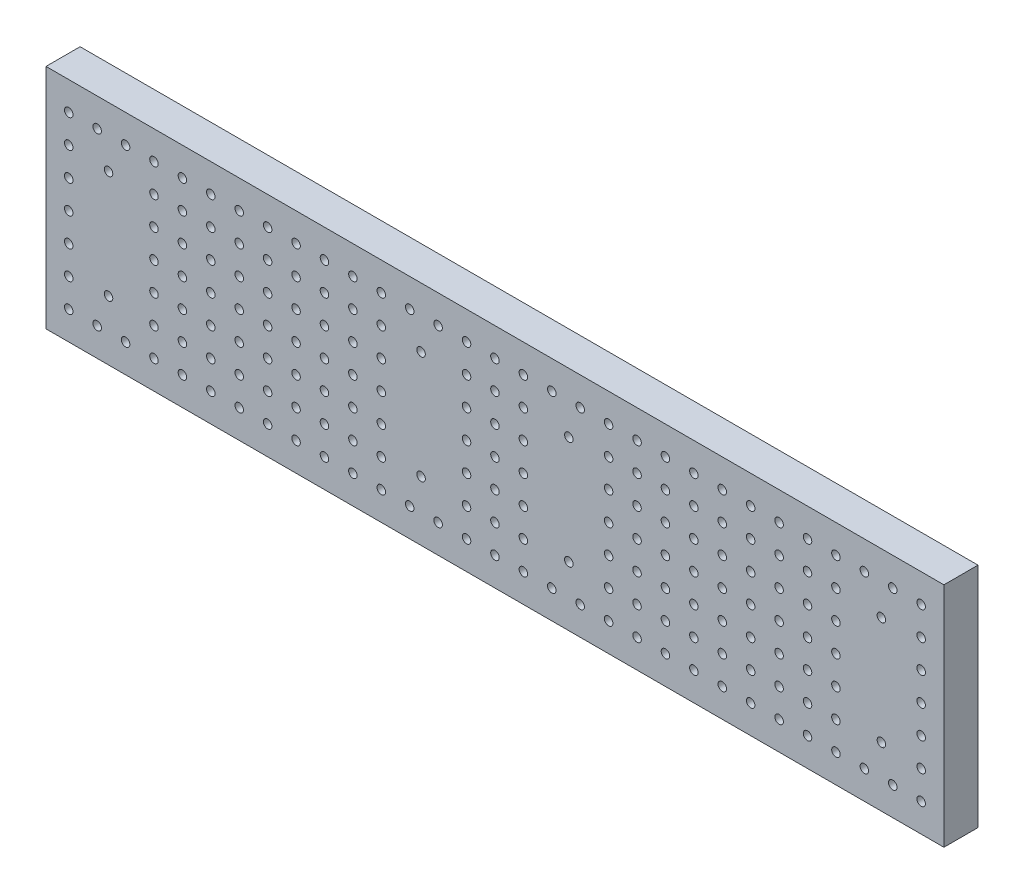
from build123d import *

# Parameters (mm, degrees)
SKETCH_1_W          = 158
SKETCH_1_H          = 40
SKETCH_1_R          = 0.75
EXTRUDE_1_DEPTH     = 6
SKETCH_2_R          = 0.75
CUT_EXTRUDE_1_DEPTH = 6


with BuildPart() as part:
    # Эскиз1 → Бобышка-Вытянуть1 (new body)
    with BuildSketch(Plane.XY):
        with Locations((79, 20)):
            Rectangle(SKETCH_1_W, SKETCH_1_H)
        with Locations((11, 29.5)):
            Circle(SKETCH_1_R, mode=Mode.SUBTRACT)
        with Locations((66, 29.5)):
            Circle(SKETCH_1_R, mode=Mode.SUBTRACT)
        with Locations((66, 10.5)):
            Circle(SKETCH_1_R, mode=Mode.SUBTRACT)
        with Locations((11, 10.5)):
            Circle(SKETCH_1_R, mode=Mode.SUBTRACT)
        with Locations((92, 10.5)):
            Circle(SKETCH_1_R, mode=Mode.SUBTRACT)
        with Locations((92, 29.5)):
            Circle(SKETCH_1_R, mode=Mode.SUBTRACT)
        with Locations((147, 10.5)):
            Circle(SKETCH_1_R, mode=Mode.SUBTRACT)
        with Locations((147, 29.5)):
            Circle(SKETCH_1_R, mode=Mode.SUBTRACT)
    extrude(amount=EXTRUDE_1_DEPTH)

    # Эскиз2 → Вырез-Вытянуть1 (cut)
    with BuildSketch(Plane.XY.offset(6)):
        with Locations((4, 35)):
            Circle(SKETCH_2_R)
        with Locations((9, 35)):
            Circle(SKETCH_2_R)
        with Locations((14, 35)):
            Circle(SKETCH_2_R)
        with Locations((19, 35)):
            Circle(SKETCH_2_R)
        with Locations((24, 35)):
            Circle(SKETCH_2_R)
        with Locations((29, 35)):
            Circle(SKETCH_2_R)
        with Locations((34, 35)):
            Circle(SKETCH_2_R)
        with Locations((39, 35)):
            Circle(SKETCH_2_R)
        with Locations((44, 35)):
            Circle(SKETCH_2_R)
        with Locations((49, 35)):
            Circle(SKETCH_2_R)
        with Locations((54, 35)):
            Circle(SKETCH_2_R)
        with Locations((59, 35)):
            Circle(SKETCH_2_R)
        with Locations((64, 35)):
            Circle(SKETCH_2_R)
        with Locations((69, 35)):
            Circle(SKETCH_2_R)
        with Locations((74, 35)):
            Circle(SKETCH_2_R)
        with Locations((79, 35)):
            Circle(SKETCH_2_R)
        with Locations((84, 35)):
            Circle(SKETCH_2_R)
        with Locations((89, 35)):
            Circle(SKETCH_2_R)
        with Locations((94, 35)):
            Circle(SKETCH_2_R)
        with Locations((99, 35)):
            Circle(SKETCH_2_R)
        with Locations((104, 35)):
            Circle(SKETCH_2_R)
        with Locations((109, 35)):
            Circle(SKETCH_2_R)
        with Locations((114, 35)):
            Circle(SKETCH_2_R)
        with Locations((119, 35)):
            Circle(SKETCH_2_R)
        with Locations((124, 35)):
            Circle(SKETCH_2_R)
        with Locations((129, 35)):
            Circle(SKETCH_2_R)
        with Locations((134, 35)):
            Circle(SKETCH_2_R)
        with Locations((139, 35)):
            Circle(SKETCH_2_R)
        with Locations((144, 35)):
            Circle(SKETCH_2_R)
        with Locations((149, 35)):
            Circle(SKETCH_2_R)
        with Locations((154, 35)):
            Circle(SKETCH_2_R)
        with Locations((19, 30)):
            Circle(SKETCH_2_R)
        with Locations((24, 30)):
            Circle(SKETCH_2_R)
        with Locations((29, 30)):
            Circle(SKETCH_2_R)
        with Locations((34, 30)):
            Circle(SKETCH_2_R)
        with Locations((39, 30)):
            Circle(SKETCH_2_R)
        with Locations((44, 30)):
            Circle(SKETCH_2_R)
        with Locations((49, 30)):
            Circle(SKETCH_2_R)
        with Locations((54, 30)):
            Circle(SKETCH_2_R)
        with Locations((59, 30)):
            Circle(SKETCH_2_R)
        with Locations((74, 30)):
            Circle(SKETCH_2_R)
        with Locations((79, 30)):
            Circle(SKETCH_2_R)
        with Locations((84, 30)):
            Circle(SKETCH_2_R)
        with Locations((99, 30)):
            Circle(SKETCH_2_R)
        with Locations((104, 30)):
            Circle(SKETCH_2_R)
        with Locations((109, 30)):
            Circle(SKETCH_2_R)
        with Locations((114, 30)):
            Circle(SKETCH_2_R)
        with Locations((119, 30)):
            Circle(SKETCH_2_R)
        with Locations((124, 30)):
            Circle(SKETCH_2_R)
        with Locations((129, 30)):
            Circle(SKETCH_2_R)
        with Locations((134, 30)):
            Circle(SKETCH_2_R)
        with Locations((139, 30)):
            Circle(SKETCH_2_R)
        with Locations((154, 30)):
            Circle(SKETCH_2_R)
        with Locations((19, 25)):
            Circle(SKETCH_2_R)
        with Locations((24, 25)):
            Circle(SKETCH_2_R)
        with Locations((29, 25)):
            Circle(SKETCH_2_R)
        with Locations((34, 25)):
            Circle(SKETCH_2_R)
        with Locations((39, 25)):
            Circle(SKETCH_2_R)
        with Locations((44, 25)):
            Circle(SKETCH_2_R)
        with Locations((49, 25)):
            Circle(SKETCH_2_R)
        with Locations((54, 25)):
            Circle(SKETCH_2_R)
        with Locations((59, 25)):
            Circle(SKETCH_2_R)
        with Locations((74, 25)):
            Circle(SKETCH_2_R)
        with Locations((79, 25)):
            Circle(SKETCH_2_R)
        with Locations((84, 25)):
            Circle(SKETCH_2_R)
        with Locations((99, 25)):
            Circle(SKETCH_2_R)
        with Locations((104, 25)):
            Circle(SKETCH_2_R)
        with Locations((109, 25)):
            Circle(SKETCH_2_R)
        with Locations((114, 25)):
            Circle(SKETCH_2_R)
        with Locations((119, 25)):
            Circle(SKETCH_2_R)
        with Locations((124, 25)):
            Circle(SKETCH_2_R)
        with Locations((129, 25)):
            Circle(SKETCH_2_R)
        with Locations((134, 25)):
            Circle(SKETCH_2_R)
        with Locations((139, 25)):
            Circle(SKETCH_2_R)
        with Locations((154, 25)):
            Circle(SKETCH_2_R)
        with Locations((19, 20)):
            Circle(SKETCH_2_R)
        with Locations((24, 20)):
            Circle(SKETCH_2_R)
        with Locations((29, 20)):
            Circle(SKETCH_2_R)
        with Locations((34, 20)):
            Circle(SKETCH_2_R)
        with Locations((39, 20)):
            Circle(SKETCH_2_R)
        with Locations((44, 20)):
            Circle(SKETCH_2_R)
        with Locations((49, 20)):
            Circle(SKETCH_2_R)
        with Locations((54, 20)):
            Circle(SKETCH_2_R)
        with Locations((59, 20)):
            Circle(SKETCH_2_R)
        with Locations((74, 20)):
            Circle(SKETCH_2_R)
        with Locations((79, 20)):
            Circle(SKETCH_2_R)
        with Locations((84, 20)):
            Circle(SKETCH_2_R)
        with Locations((99, 20)):
            Circle(SKETCH_2_R)
        with Locations((104, 20)):
            Circle(SKETCH_2_R)
        with Locations((109, 20)):
            Circle(SKETCH_2_R)
        with Locations((114, 20)):
            Circle(SKETCH_2_R)
        with Locations((119, 20)):
            Circle(SKETCH_2_R)
        with Locations((124, 20)):
            Circle(SKETCH_2_R)
        with Locations((129, 20)):
            Circle(SKETCH_2_R)
        with Locations((134, 20)):
            Circle(SKETCH_2_R)
        with Locations((139, 20)):
            Circle(SKETCH_2_R)
        with Locations((154, 20)):
            Circle(SKETCH_2_R)
        with Locations((19, 15)):
            Circle(SKETCH_2_R)
        with Locations((24, 15)):
            Circle(SKETCH_2_R)
        with Locations((29, 15)):
            Circle(SKETCH_2_R)
        with Locations((34, 15)):
            Circle(SKETCH_2_R)
        with Locations((39, 15)):
            Circle(SKETCH_2_R)
        with Locations((44, 15)):
            Circle(SKETCH_2_R)
        with Locations((49, 15)):
            Circle(SKETCH_2_R)
        with Locations((54, 15)):
            Circle(SKETCH_2_R)
        with Locations((59, 15)):
            Circle(SKETCH_2_R)
        with Locations((74, 15)):
            Circle(SKETCH_2_R)
        with Locations((79, 15)):
            Circle(SKETCH_2_R)
        with Locations((84, 15)):
            Circle(SKETCH_2_R)
        with Locations((99, 15)):
            Circle(SKETCH_2_R)
        with Locations((104, 15)):
            Circle(SKETCH_2_R)
        with Locations((109, 15)):
            Circle(SKETCH_2_R)
        with Locations((114, 15)):
            Circle(SKETCH_2_R)
        with Locations((119, 15)):
            Circle(SKETCH_2_R)
        with Locations((124, 15)):
            Circle(SKETCH_2_R)
        with Locations((129, 15)):
            Circle(SKETCH_2_R)
        with Locations((134, 15)):
            Circle(SKETCH_2_R)
        with Locations((139, 15)):
            Circle(SKETCH_2_R)
        with Locations((154, 15)):
            Circle(SKETCH_2_R)
        with Locations((19, 10)):
            Circle(SKETCH_2_R)
        with Locations((24, 10)):
            Circle(SKETCH_2_R)
        with Locations((29, 10)):
            Circle(SKETCH_2_R)
        with Locations((34, 10)):
            Circle(SKETCH_2_R)
        with Locations((39, 10)):
            Circle(SKETCH_2_R)
        with Locations((44, 10)):
            Circle(SKETCH_2_R)
        with Locations((49, 10)):
            Circle(SKETCH_2_R)
        with Locations((54, 10)):
            Circle(SKETCH_2_R)
        with Locations((59, 10)):
            Circle(SKETCH_2_R)
        with Locations((74, 10)):
            Circle(SKETCH_2_R)
        with Locations((79, 10)):
            Circle(SKETCH_2_R)
        with Locations((84, 10)):
            Circle(SKETCH_2_R)
        with Locations((99, 10)):
            Circle(SKETCH_2_R)
        with Locations((104, 10)):
            Circle(SKETCH_2_R)
        with Locations((109, 10)):
            Circle(SKETCH_2_R)
        with Locations((114, 10)):
            Circle(SKETCH_2_R)
        with Locations((119, 10)):
            Circle(SKETCH_2_R)
        with Locations((124, 10)):
            Circle(SKETCH_2_R)
        with Locations((129, 10)):
            Circle(SKETCH_2_R)
        with Locations((134, 10)):
            Circle(SKETCH_2_R)
        with Locations((139, 10)):
            Circle(SKETCH_2_R)
        with Locations((154, 10)):
            Circle(SKETCH_2_R)
        with Locations((9, 5)):
            Circle(SKETCH_2_R)
        with Locations((14, 5)):
            Circle(SKETCH_2_R)
        with Locations((19, 5)):
            Circle(SKETCH_2_R)
        with Locations((24, 5)):
            Circle(SKETCH_2_R)
        with Locations((29, 5)):
            Circle(SKETCH_2_R)
        with Locations((34, 5)):
            Circle(SKETCH_2_R)
        with Locations((39, 5)):
            Circle(SKETCH_2_R)
        with Locations((44, 5)):
            Circle(SKETCH_2_R)
        with Locations((49, 5)):
            Circle(SKETCH_2_R)
        with Locations((54, 5)):
            Circle(SKETCH_2_R)
        with Locations((59, 5)):
            Circle(SKETCH_2_R)
        with Locations((64, 5)):
            Circle(SKETCH_2_R)
        with Locations((69, 5)):
            Circle(SKETCH_2_R)
        with Locations((74, 5)):
            Circle(SKETCH_2_R)
        with Locations((79, 5)):
            Circle(SKETCH_2_R)
        with Locations((84, 5)):
            Circle(SKETCH_2_R)
        with Locations((89, 5)):
            Circle(SKETCH_2_R)
        with Locations((94, 5)):
            Circle(SKETCH_2_R)
        with Locations((99, 5)):
            Circle(SKETCH_2_R)
        with Locations((104, 5)):
            Circle(SKETCH_2_R)
        with Locations((109, 5)):
            Circle(SKETCH_2_R)
        with Locations((114, 5)):
            Circle(SKETCH_2_R)
        with Locations((119, 5)):
            Circle(SKETCH_2_R)
        with Locations((124, 5)):
            Circle(SKETCH_2_R)
        with Locations((129, 5)):
            Circle(SKETCH_2_R)
        with Locations((134, 5)):
            Circle(SKETCH_2_R)
        with Locations((139, 5)):
            Circle(SKETCH_2_R)
        with Locations((144, 5)):
            Circle(SKETCH_2_R)
        with Locations((149, 5)):
            Circle(SKETCH_2_R)
        with Locations((154, 5)):
            Circle(SKETCH_2_R)
        with Locations((4, 30)):
            Circle(SKETCH_2_R)
        with Locations((4, 25)):
            Circle(SKETCH_2_R)
        with Locations((4, 20)):
            Circle(SKETCH_2_R)
        with Locations((4, 15)):
            Circle(SKETCH_2_R)
        with Locations((4, 10)):
            Circle(SKETCH_2_R)
        with Locations((4, 5)):
            Circle(SKETCH_2_R)
    extrude(amount=-CUT_EXTRUDE_1_DEPTH, mode=Mode.SUBTRACT)


solid = part.part
